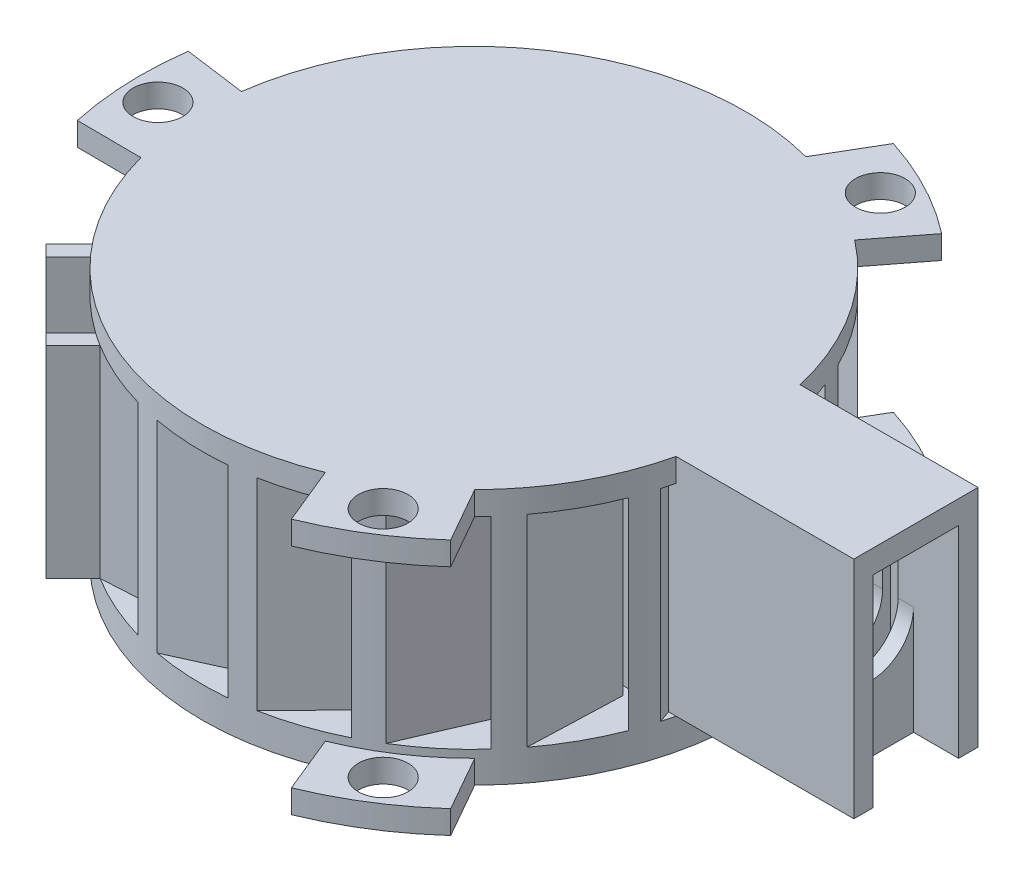
from build123d import *

# Parameters (mm, degrees)
SKETCH1_R           = 17.5
BOSS_EXTRUDE1_DEPTH = 2
BOSS_EXTRUDE2_DEPTH = 13
SKETCH7_W           = 17
SKETCH7_H           = 8
BOSS_EXTRUDE3_DEPTH = 13
SKETCH8_W           = 15
SKETCH8_H           = 5.5
CUT_EXTRUDE1_DEPTH  = 6
SKETCH10_W          = 3.5
SKETCH10_H          = 5.5
CUT_EXTRUDE2_DEPTH  = 6
CUT_EXTRUDE3_START  = -1
SKETCH14_R          = 2.75
CUT_EXTRUDE3_DEPTH  = 13
SKETCH15_W          = 1.905618148
SKETCH15_H          = 1.75
CUT_EXTRUDE4_DEPTH  = 13
SKETCH16_W          = 2.905618148
SKETCH16_H          = 5.502957148
CUT_EXTRUDE5_DEPTH  = 13
SKETCH17_W          = 1
SKETCH17_H          = 0.5
SKETCH17_H_2        = 5.5
CUT_EXTRUDE6_DEPTH  = 10
SKETCH18_R          = 2
CUT_EXTRUDE7_DEPTH  = 10
BOSS_EXTRUDE4_DEPTH = 13
CUT_EXTRUDE8_DEPTH  = 6
CUT_EXTRUDE9_DEPTH  = 7
SKETCH23_R          = 2.6
CUT_EXTRUDE10_DEPTH = 3
CUT_EXTRUDE11_DEPTH = 22
CUT_EXTRUDE12_DEPTH = 17
CUT_EXTRUDE15_DEPTH = 22
BOSS_EXTRUDE5_DEPTH = 13
CUT_EXTRUDE16_DEPTH = 13
BOSS_EXTRUDE6_DEPTH = 1.5
SKETCH31_R          = 1.6
CUT_EXTRUDE17_DEPTH = 16.5
SKETCH32_R          = 1.6
BOSS_EXTRUDE7_DEPTH = 1.5


with BuildPart() as part:
    # Sketch1 → Boss-Extrude1 (new body)
    with BuildSketch(Plane(origin=(0, 0, 0), x_dir=(1, 0, 0), z_dir=(0, 1, 0))):
        Circle(SKETCH1_R)
    extrude(amount=BOSS_EXTRUDE1_DEPTH)

    # Sketch6 → Boss-Extrude2 (add)
    with BuildSketch(Plane(origin=(0, 2, 0), x_dir=(1, 0, 0), z_dir=(0, 1, 0))):
        with BuildLine():
            Line((0, 17.5), (-4.914912266, 14.058541382))
            Line((-4.914912266, 14.058541382), (-4.341335829, 13.239389338))
            Line((-4.341335829, 13.239389338), (-1.777576333, 15.034553063))
            Line((-1.777576333, 15.034553063), (-0.580505831, 11.745628891))
            Line((-0.580505831, 11.745628891), (0.18864202, 12.284192014))
            Line((0.18864202, 12.284192014), (-1.008428482, 15.573116187))
            Line((-1.008428482, 15.573116187), (1.634231764, 17.423526811))
            ThreePointArc((1.634231764, 17.423526811), (0.818010025, 17.480871248), (0, 17.5))
        make_face()
        with BuildLine():
            Line((6.321729158, 16.318264015), (0.495511715, 14.884670521))
            Line((0.495511715, 14.884670521), (0.734443964, 13.91363428))
            Line((0.734443964, 13.91363428), (3.773566433, 14.661437849))
            Line((3.773566433, 14.661437849), (3.701704984, 11.162175651))
            Line((3.701704984, 11.162175651), (4.613465436, 11.386522556))
            Line((4.613465436, 11.386522556), (4.685326884, 14.885784754))
            Line((4.685326884, 14.885784754), (7.817979592, 15.656602285))
            ThreePointArc((7.817979592, 15.656602285), (7.077590688, 16.00492768), (6.321729158, 16.318264015))
        make_face()
        with BuildLine():
            Line((11.789673764, 12.932656051), (5.839014093, 13.700542427))
            Line((5.839014093, 13.700542427), (5.711033031, 12.708765815))
            Line((5.711033031, 12.708765815), (8.815068142, 12.308214212))
            Line((8.815068142, 12.308214212), (7.48398003, 9.071208738))
            Line((7.48398003, 9.071208738), (8.41521478, 8.951040132))
            Line((8.41521478, 8.951040132), (9.746302893, 12.188045606))
            Line((9.746302893, 12.188045606), (12.945865956, 11.775166863))
            ThreePointArc((12.945865956, 11.775166863), (12.38130351, 12.367429943), (11.789673764, 12.932656051))
        make_face()
        with BuildLine():
            Line((15.665357599, 7.800421226), (10.393925263, 10.666080161))
            Line((10.393925263, 10.666080161), (9.916315441, 9.787508105))
            Line((9.916315441, 9.787508105), (12.666046052, 8.292698043))
            Line((12.666046052, 8.292698043), (10.255502102, 5.75512482))
            Line((10.255502102, 5.75512482), (11.080442739, 5.306670139))
            Line((11.080442739, 5.306670139), (13.490986689, 7.844243362))
            Line((13.490986689, 7.844243362), (16.325341387, 6.303429908))
            ThreePointArc((16.325341387, 6.303429908), (16.012852686, 7.059642261), (15.665357599, 7.800421226))
        make_face()
        with BuildLine():
            Line((17.425348085, 1.614696291), (13.545079231, 6.191104666))
            Line((13.545079231, 6.191104666), (12.782344502, 5.544393191))
            Line((12.782344502, 5.544393191), (14.806404258, 3.157207052))
            Line((14.806404258, 3.157207052), (11.641961788, 1.661779404))
            Line((11.641961788, 1.661779404), (12.249195506, 0.945604938))
            Line((12.249195506, 0.945604938), (15.413637977, 2.441032586))
            Line((15.413637977, 2.441032586), (17.499989001, -0.019620184))
            ThreePointArc((17.499989001, -0.019620184), (17.481777376, 0.798410773), (17.425348085, 1.614696291))
        make_face()
        with BuildLine():
            Line((16.831948756, -4.789102326), (14.866895193, 0.879986181))
            Line((14.866895193, 0.879986181), (13.922047109, 0.552477253))
            Line((13.922047109, 0.552477253), (14.947075524, -2.404682246))
            Line((14.947075524, -2.404682246), (11.456110024, -2.655998528))
            Line((11.456110024, -2.655998528), (11.763626545, -3.543169449))
            Line((11.763626545, -3.543169449), (15.254592046, -3.291853167))
            Line((15.254592046, -3.291853167), (16.311166131, -6.340020462))
            ThreePointArc((16.311166131, -6.340020462), (16.589691162, -5.570650514), (16.831948756, -4.789102326))
        make_face()
        with BuildLine():
            Line((13.965301477, -10.546106137), (14.180854579, -4.549979315))
            Line((14.180854579, -4.549979315), (13.181500109, -4.514053798))
            Line((13.181500109, -4.514053798), (13.069061416, -7.641805882))
            Line((13.069061416, -7.641805882), (9.72304712, -6.615069142))
            Line((9.72304712, -6.615069142), (9.689314635, -7.553419169))
            Line((9.689314635, -7.553419169), (13.035328931, -8.580155909))
            Line((13.035328931, -8.580155909), (12.919429891, -11.804165845))
            ThreePointArc((12.919429891, -11.804165845), (13.45707523, -11.187364581), (13.965301477, -10.546106137))
        make_face()
        with BuildLine():
            Line((9.21256285, -14.878799875), (11.579610976, -9.365444892))
            Line((11.579610976, -9.365444892), (10.660718478, -8.970936871))
            Line((10.660718478, -8.970936871), (9.425998145, -11.846861289))
            Line((9.425998145, -11.846861289), (6.676832826, -9.680738012))
            Line((6.676832826, -9.680738012), (6.306407093, -10.543537775))
            Line((6.306407093, -10.543537775), (9.055572412, -12.709661052))
            Line((9.055572412, -12.709661052), (7.782853055, -15.674093222))
            ThreePointArc((7.782853055, -15.674093222), (8.50700672, -15.29316307), (9.21256285, -14.878799875))
        make_face()
        with BuildLine():
            Line((3.215616562, -17.202029244), (7.414476745, -12.91605524))
            Line((7.414476745, -12.91605524), (6.700147744, -12.21624521))
            Line((6.700147744, -12.21624521), (4.509901594, -14.451932433))
            Line((4.509901594, -14.451932433), (2.728875261, -11.438969572))
            Line((2.728875261, -11.438969572), (2.071784328, -12.109693181))
            Line((2.071784328, -12.109693181), (3.852810661, -15.122656042))
            Line((3.852810661, -15.122656042), (1.595158788, -17.427147456))
            ThreePointArc((1.595158788, -17.427147456), (2.408019813, -17.333535144), (3.215616562, -17.202029244))
        make_face()
        with BuildLine():
            Line((-3.215616562, -17.202029244), (2.247976344, -14.722280758))
            Line((2.247976344, -14.722280758), (1.83468493, -13.81168194))
            Line((1.83468493, -13.81168194), (-1.015282158, -15.105190021))
            Line((-1.015282158, -15.105190021), (-1.587632029, -11.652304905))
            Line((-1.587632029, -11.652304905), (-2.44264439, -12.040367421))
            Line((-2.44264439, -12.040367421), (-1.87029452, -15.493252537))
            Line((-1.87029452, -15.493252537), (-4.807970512, -16.826568859))
            ThreePointArc((-4.807970512, -16.826568859), (-4.016183513, -17.032917248), (-3.215616562, -17.202029244))
        make_face()
        with BuildLine():
            Line((-9.21256285, -14.878799875), (-3.222125718, -14.540180681))
            Line((-3.222125718, -14.540180681), (-3.27856225, -13.541774492))
            Line((-3.27856225, -13.541774492), (-6.403346429, -13.718407996))
            Line((-6.403346429, -13.718407996), (-5.689720816, -10.291931893))
            Line((-5.689720816, -10.291931893), (-6.627180449, -10.344923322))
            Line((-6.627180449, -10.344923322), (-7.340806061, -13.771399425))
            Line((-7.340806061, -13.771399425), (-10.561756753, -13.953468898))
            ThreePointArc((-10.561756753, -13.953468898), (-9.897979001, -14.431909496), (-9.21256285, -14.878799875))
        make_face()
        with BuildLine():
            Line((-13.965301477, -10.546106137), (-8.257061847, -12.394348632))
            Line((-8.257061847, -12.394348632), (-7.949021431, -11.442975361))
            Line((-7.949021431, -11.442975361), (-10.926603282, -10.478878955))
            Line((-10.926603282, -10.478878955), (-9.02338128, -7.541576449))
            Line((-9.02338128, -7.541576449), (-9.916679065, -7.252340006))
            Line((-9.916679065, -7.252340006), (-11.819901068, -10.189642511))
            Line((-11.819901068, -10.189642511), (-14.88911922, -9.195875644))
            ThreePointArc((-14.88911922, -9.195875644), (-14.442997578, -9.881792396), (-13.965301477, -10.546106137))
        make_face()
        with BuildLine():
            Line((-16.831948756, -4.789102326), (-12.17683602, -8.574591122))
            Line((-12.17683602, -8.574591122), (-11.545921221, -7.798738999))
            Line((-11.545921221, -7.798738999), (-13.974161816, -5.824119245))
            Line((-13.974161816, -5.824119245), (-11.138384101, -3.772689317))
            Line((-11.138384101, -3.772689317), (-11.866875224, -3.180287985))
            Line((-11.866875224, -3.180287985), (-14.702652939, -5.231717913))
            Line((-14.702652939, -5.231717913), (-17.205623632, -3.196328428))
            ThreePointArc((-17.205623632, -3.196328428), (-17.037409301, -3.997084476), (-16.831948756, -4.789102326))
        make_face()
        with BuildLine():
            Line((-17.425348085, 1.614696291), (-14.452061014, -3.596787567))
            Line((-14.452061014, -3.596787567), (-13.583480372, -3.101239722))
            Line((-13.583480372, -3.101239722), (-15.134432363, -0.382779959))
            Line((-15.134432363, -0.382779959), (-11.749086429, 0.505720413))
            Line((-11.749086429, 0.505720413), (-12.214384127, 1.321279551))
            Line((-12.214384127, 1.321279551), (-15.59973006, 0.432779179))
            Line((-15.59973006, 0.432779179), (-17.198413234, 3.234900654))
            ThreePointArc((-17.198413234, 3.234900654), (-17.33082449, 2.427451851), (-17.425348085, 1.614696291))
        make_face()
        with BuildLine():
            Line((-15.665357599, 7.800421226), (-14.775455087, 1.86678208))
            Line((-14.775455087, 1.86678208), (-13.786515229, 2.015099165))
            Line((-13.786515229, 2.015099165), (-14.250713956, 5.110255882))
            Line((-14.250713956, 5.110255882), (-10.773009531, 4.715829799))
            Line((-10.773009531, 4.715829799), (-10.912272771, 5.644400962))
            Line((-10.912272771, 5.644400962), (-14.389977196, 6.038827045))
            Line((-14.389977196, 6.038827045), (-14.868461828, 9.229238477))
            ThreePointArc((-14.868461828, 9.229238477), (-15.283615799, 8.524147354), (-15.665357599, 7.800421226))
        make_face()
        with BuildLine():
            Line((-11.789673764, 12.932656051), (-13.103342077, 7.078232462))
            Line((-13.103342077, 7.078232462), (-12.127604812, 6.859287743))
            Line((-12.127604812, 6.859287743), (-11.442357664, 9.913123349))
            Line((-11.442357664, 9.913123349), (-8.341978001, 8.289040239))
            Line((-8.341978001, 8.289040239), (-8.136398511, 9.205214746))
            Line((-8.136398511, 9.205214746), (-11.236778173, 10.829297856))
            Line((-11.236778173, 10.829297856), (-10.530442264, 13.977116503))
            ThreePointArc((-10.530442264, 13.977116503), (-11.172270104, 13.469609524), (-11.789673764, 12.932656051))
        make_face()
        with BuildLine():
            Line((-6.321729158, 16.318264015), (-9.661550111, 11.333728329))
            Line((-9.661550111, 11.333728329), (-8.830794163, 10.777091503))
            Line((-8.830794163, 10.777091503), (-7.088647565, 13.377168577))
            Line((-7.088647565, 13.377168577), (-4.784316117, 10.742769864))
            Line((-4.784316117, 10.742769864), (-4.261658546, 11.522813271))
            Line((-4.261658546, 11.522813271), (-6.565989994, 14.157211984))
            Line((-6.565989994, 14.157211984), (-4.77022812, 16.837307495))
            ThreePointArc((-4.77022812, 16.837307495), (-5.552047424, 16.595926289), (-6.321729158, 16.318264015))
        make_face()
    extrude(amount=BOSS_EXTRUDE2_DEPTH)

    # Sketch7 → Boss-Extrude3 (add)
    with BuildSketch(Plane(origin=(0, 2, 0), x_dir=(1, 0, 0), z_dir=(0, 1, 0))):
        with Locations((20, 0)):
            Rectangle(SKETCH7_W, SKETCH7_H)
    extrude(amount=BOSS_EXTRUDE3_DEPTH)

    # Sketch8 → Cut-Extrude1 (cut)
    with BuildSketch(Plane(origin=(0, 15, 0), x_dir=(1, 0, 0), z_dir=(0, 1, 0))):
        with Locations((20, 0)):
            Rectangle(SKETCH8_W, SKETCH8_H)
    extrude(amount=-CUT_EXTRUDE1_DEPTH, mode=Mode.SUBTRACT)

    # Sketch10 → Cut-Extrude2 (cut)
    with BuildSketch(Plane(origin=(0, 9, 0), x_dir=(1, 0, 0), z_dir=(0, 1, 0))):
        with Locations((14.25, 0)):
            Rectangle(SKETCH10_W, SKETCH10_H)
    extrude(amount=-CUT_EXTRUDE2_DEPTH, mode=Mode.SUBTRACT)

    # Sketch14 → Cut-Extrude3 (cut)
    with BuildSketch(Plane(origin=(28.5, 0, 0), x_dir=(0, 0, -1), z_dir=(1, 0, 0)).offset(CUT_EXTRUDE3_START)):
        with Locations((0, 9)):
            Circle(SKETCH14_R)
    extrude(amount=-CUT_EXTRUDE3_DEPTH, mode=Mode.SUBTRACT)

    # Sketch15 → Cut-Extrude4 (cut)
    with BuildSketch(Plane(origin=(0, 15, 0), x_dir=(1, 0, 0), z_dir=(0, 1, 0))):
        with Locations((26.547190926, -1.875)):
            Rectangle(SKETCH15_W, SKETCH15_H)
        with Locations((26.547190926, 1.875)):
            Rectangle(SKETCH15_W, SKETCH15_H)
    extrude(amount=-CUT_EXTRUDE4_DEPTH, mode=Mode.SUBTRACT)

    # Sketch16 → Cut-Extrude5 (cut)
    with BuildSketch(Plane(origin=(0, 15, 0), x_dir=(1, 0, 0), z_dir=(0, 1, 0))):
        with Locations((27.047190926, -0.001478574)):
            Rectangle(SKETCH16_W, SKETCH16_H)
    extrude(amount=-CUT_EXTRUDE5_DEPTH, mode=Mode.SUBTRACT)

    # Sketch17 → Cut-Extrude6 (cut)
    with BuildSketch(Plane(origin=(0, 15, 0), x_dir=(1, 0, 0), z_dir=(0, 1, 0))):
        with Locations((24.1, 3)):
            Rectangle(SKETCH17_W, SKETCH17_H)
        with Locations((24.1, 0)):
            Rectangle(SKETCH17_W, SKETCH17_H_2)
        with Locations((24.1, -3)):
            Rectangle(SKETCH17_W, SKETCH17_H)
    extrude(amount=-CUT_EXTRUDE6_DEPTH, mode=Mode.SUBTRACT)

    # Sketch18 → Cut-Extrude7 (cut)
    with BuildSketch(Plane(origin=(12.5, 0, 0), x_dir=(0, 0, -1), z_dir=(1, 0, 0))):
        with Locations((0, 9)):
            Circle(SKETCH18_R)
    extrude(amount=-CUT_EXTRUDE7_DEPTH, mode=Mode.SUBTRACT)

    # Sketch20 → Boss-Extrude4 (add)
    with BuildSketch(Plane(origin=(0, 2, 0), x_dir=(1, 0, 0), z_dir=(0, 1, 0))):
        Polygon((-22.980970389, -17.324116139), (-10.960155108, -5.303300859), (-5.303300859, -10.960155108), (-17.324116139, -22.980970389), align=None)
    extrude(amount=BOSS_EXTRUDE4_DEPTH)

    # Sketch21 → Cut-Extrude8 (cut)
    with BuildSketch(Plane(origin=(0, 15, 0), x_dir=(1, 0, 0), z_dir=(0, 1, 0))):
        Polygon((-17.324116139, -21.566756826), (-6.717514421, -10.960155108), (-10.960155108, -6.717514421), (-21.566756826, -17.324116139), align=None)
    extrude(amount=-CUT_EXTRUDE8_DEPTH, mode=Mode.SUBTRACT)

    # Sketch22 → Cut-Extrude9 (cut)
    with BuildSketch(Plane(origin=(0, 9, 0), x_dir=(1, 0, 0), z_dir=(0, 1, 0))):
        Polygon((-10.960155108, -6.717514421), (-6.717514421, -10.960155108), (-9.545941546, -13.788582233), (-13.788582233, -9.545941546), align=None)
    extrude(amount=-CUT_EXTRUDE9_DEPTH, mode=Mode.SUBTRACT)

    # Sketch23 → Cut-Extrude10 (cut)
    with BuildSketch(Plane(origin=(-11.66726189, 0, 11.66726189), x_dir=(-0.707106781, 0, -0.707106781), z_dir=(0.707106781, 0, -0.707106781))):
        with Locations((0, 9)):
            Circle(SKETCH23_R)
    extrude(amount=-CUT_EXTRUDE10_DEPTH, mode=Mode.SUBTRACT)

    # Sketch24 → Cut-Extrude11 (cut)
    with BuildSketch(Plane(origin=(0, 15, 0), x_dir=(1, 0, 0), z_dir=(0, 1, 0))):
        Polygon((-22.980970389, -17.324116139), (-16.617009358, -10.960155108), (-10.960155108, -16.617009358), (-17.324116139, -22.980970389), align=None)
    extrude(amount=-CUT_EXTRUDE11_DEPTH, mode=Mode.SUBTRACT)

    # Sketch25 → Cut-Extrude12 (cut)
    with BuildSketch(Plane(origin=(-13.788582233, 0, 13.788582233), x_dir=(0.707106781, 0, 0.707106781), z_dir=(-0.707106781, 0, 0.707106781))):
        with BuildLine():
            ThreePointArc((2.6, 9), (0, 11.6), (-2.6, 9))
            ThreePointArc((-2.6, 9), (0, 6.4), (2.6, 9))
        make_face()
    extrude(amount=-CUT_EXTRUDE12_DEPTH, mode=Mode.SUBTRACT)

    # Sketch27 → Cut-Extrude15 (cut)
    with BuildSketch(Plane(origin=(0, 15, 0), x_dir=(1, 0, 0), z_dir=(0, 1, 0))):
        Polygon((-11.313708499, -9.192388155), (-10.960155108, -8.838834765), (-8.838834765, -10.960155108), (-9.545941546, -11.66726189), (-11.66726189, -9.545941546), align=None)
    extrude(amount=-CUT_EXTRUDE15_DEPTH, mode=Mode.SUBTRACT)

    # Sketch28 → Boss-Extrude5 (add)
    with BuildSketch(Plane(origin=(0, 2, 0), x_dir=(1, 0, 0), z_dir=(0, 1, 0))):
        Polygon((-1.911696438, -3.144998494), (1.447060773, -6.503755705), (2.154167554, -5.796648923), (3.568381116, -7.210862486), (4.275487897, -6.503755705), (2.154167554, -4.382435361), (2.154167554, -0.723337101), (1.154167554, -0.723337101), (1.154167554, -4.382435361), (1.154167554, -4.796648923), (-1.204589657, -2.437891713), align=None)
    extrude(amount=BOSS_EXTRUDE5_DEPTH)

    # Sketch29 → Cut-Extrude16 (cut)
    with BuildSketch(Plane(origin=(0, 15, 0), x_dir=(1, 0, 0), z_dir=(0, 1, 0))):
        Polygon((-5.956446946, -10.307009021), (-5.738294991, -10.525160977), (-5.689720816, -10.291931893), align=None)
    extrude(amount=-CUT_EXTRUDE16_DEPTH, mode=Mode.SUBTRACT)

    # Sketch30 → Boss-Extrude6 (add)
    with BuildSketch(Plane(origin=(0, 0, 0), x_dir=(1, 0, 0), z_dir=(0, 1, 0))):
        with BuildLine():
            Line((4.489618927, 16.91429342), (6.576131268, 20.46959935))
            ThreePointArc((6.576131268, 20.46959935), (10.020480713, 19.022091533), (13.162236094, 17.00016297))
            Line((13.162236094, 17.00016297), (10.713447983, 13.837341952))
            ThreePointArc((10.713447983, 13.837341952), (7.75565719, 15.687567738), (4.489618927, 16.91429342))
        make_face()
        with BuildLine():
            Line((12.403398325, -12.345270754), (14.439127409, -15.929896411))
            ThreePointArc((14.439127409, -15.929896411), (11.463374144, -18.189036622), (8.141454954, -19.898912313))
            Line((8.141454954, -19.898912313), (6.62676566, -16.196789092))
            ThreePointArc((6.62676566, -16.196789092), (9.70800359, -14.560380019), (12.403398325, -12.345270754))
        make_face()
        with BuildLine():
            Line((-16.893017252, -4.569022665), (-21.015258676, -4.539702939))
            ThreePointArc((-21.015258676, -4.539702939), (-21.483854857, -0.833054911), (-21.303691048, 2.898749343))
            Line((-21.303691048, 2.898749343), (-17.340213643, 2.359447139))
            ThreePointArc((-17.340213643, 2.359447139), (-17.46366078, -1.127187719), (-16.893017252, -4.569022665))
        make_face()
    extrude(amount=BOSS_EXTRUDE6_DEPTH)

    # Sketch31 → Cut-Extrude17 (cut)
    with BuildSketch(Plane(origin=(0, 2, 0), x_dir=(1, 0, 0), z_dir=(0, 1, 0))):
        with Locations((8.909814561, 17.293808881)):
            Circle(SKETCH31_R)
        with Locations((10.521970538, -16.363030193)):
            Circle(SKETCH31_R)
        with Locations((-19.431785099, -0.930778688)):
            Circle(SKETCH31_R)
    extrude(amount=-CUT_EXTRUDE17_DEPTH, mode=Mode.SUBTRACT)

    # Sketch32 → Boss-Extrude7 (add)
    with BuildSketch(Plane(origin=(0, 15, 0), x_dir=(1, 0, 0), z_dir=(0, 1, 0))):
        with BuildLine():
            Line((-17.340213643, 2.359447139), (-21.303691048, 2.898749343))
            ThreePointArc((-21.303691048, 2.898749343), (-21.483854857, -0.833054911), (-21.015258676, -4.539702939))
            Line((-21.015258676, -4.539702939), (-16.893017252, -4.569022665))
            ThreePointArc((-16.893017252, -4.569022665), (-17.46366078, -1.127187719), (-17.340213643, 2.359447139))
        make_face()
        with Locations((-19.431785099, -0.930778688)):
            Circle(SKETCH32_R, mode=Mode.SUBTRACT)
        with BuildLine():
            ThreePointArc((-16.893017252, -4.569022665), (-7.75565719, -15.687567738), (6.62676566, -16.196789092))
            ThreePointArc((6.62676566, -16.196789092), (9.70800359, -14.560380019), (12.403398325, -12.345270754))
            ThreePointArc((12.403398325, -12.345270754), (15.300036009, -8.494639375), (17.036725037, -4))
            Line((17.036725037, -4), (28.5, -4))
            Line((28.5, -4), (28.5, 4))
            Line((28.5, 4), (17.036725037, 4))
            ThreePointArc((17.036725037, 4), (14.721119178, 9.462486468), (10.713447983, 13.837341952))
            ThreePointArc((10.713447983, 13.837341952), (7.75565719, 15.687567738), (4.489618927, 16.91429342))
            ThreePointArc((4.489618927, 16.91429342), (-9.70800359, 14.560380019), (-17.340213643, 2.359447139))
            ThreePointArc((-17.340213643, 2.359447139), (-17.46366078, -1.127187719), (-16.893017252, -4.569022665))
        make_face()
        with BuildLine():
            Line((10.713447983, 13.837341952), (13.162236094, 17.00016297))
            ThreePointArc((13.162236094, 17.00016297), (10.020480713, 19.022091533), (6.576131268, 20.46959935))
            Line((6.576131268, 20.46959935), (4.489618927, 16.91429342))
            ThreePointArc((4.489618927, 16.91429342), (7.75565719, 15.687567738), (10.713447983, 13.837341952))
        make_face()
        with Locations((8.909814561, 17.293808881)):
            Circle(SKETCH32_R, mode=Mode.SUBTRACT)
        with BuildLine():
            Line((6.62676566, -16.196789092), (8.141454954, -19.898912313))
            ThreePointArc((8.141454954, -19.898912313), (11.463374144, -18.189036622), (14.439127409, -15.929896411))
            Line((14.439127409, -15.929896411), (12.403398325, -12.345270754))
            ThreePointArc((12.403398325, -12.345270754), (9.70800359, -14.560380019), (6.62676566, -16.196789092))
        make_face()
        with Locations((10.521970538, -16.363030193)):
            Circle(SKETCH32_R, mode=Mode.SUBTRACT)
    extrude(amount=BOSS_EXTRUDE7_DEPTH)


solid = part.part
